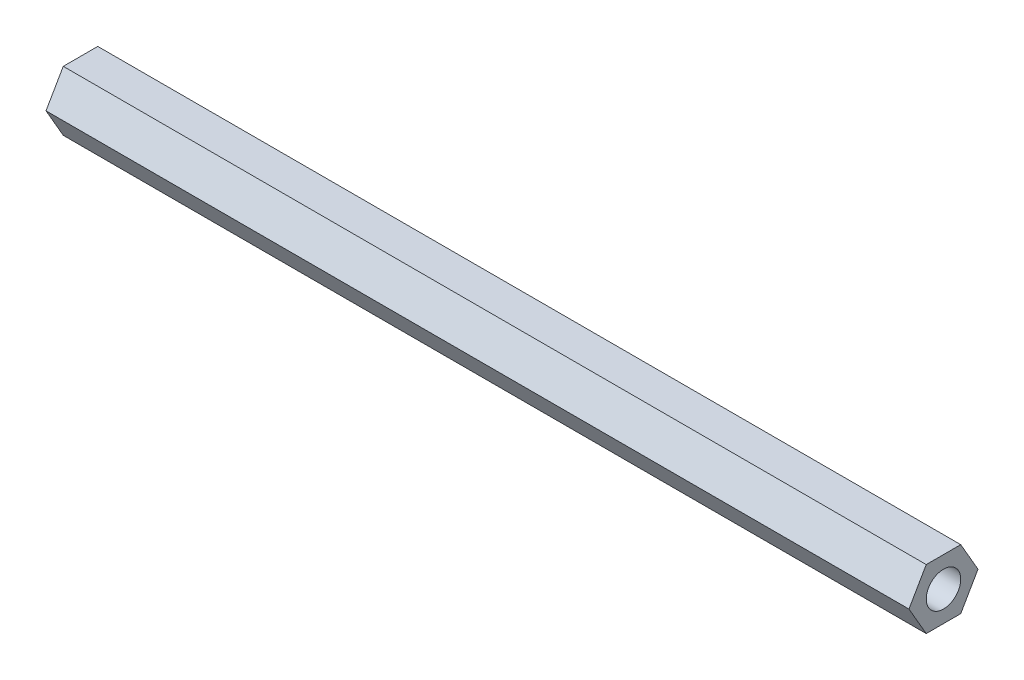
from build123d import *

# Parameters (mm, degrees)
SKETCH1_R           = 1
BOSS_EXTRUDE1_DEPTH = 50


with BuildPart() as part:
    # Sketch1 → Boss-Extrude1 (new body)
    with BuildSketch(Plane(origin=(0, 0, 0), x_dir=(0, 0, -1), z_dir=(1, 0, 0))):
        Polygon((1, 1.732050808), (-1, 1.732050808), (-2, 0), (-1, -1.732050808), (1, -1.732050808), (2, 0), align=None)
        Circle(SKETCH1_R, mode=Mode.SUBTRACT)
    extrude(amount=BOSS_EXTRUDE1_DEPTH)


solid = part.part
